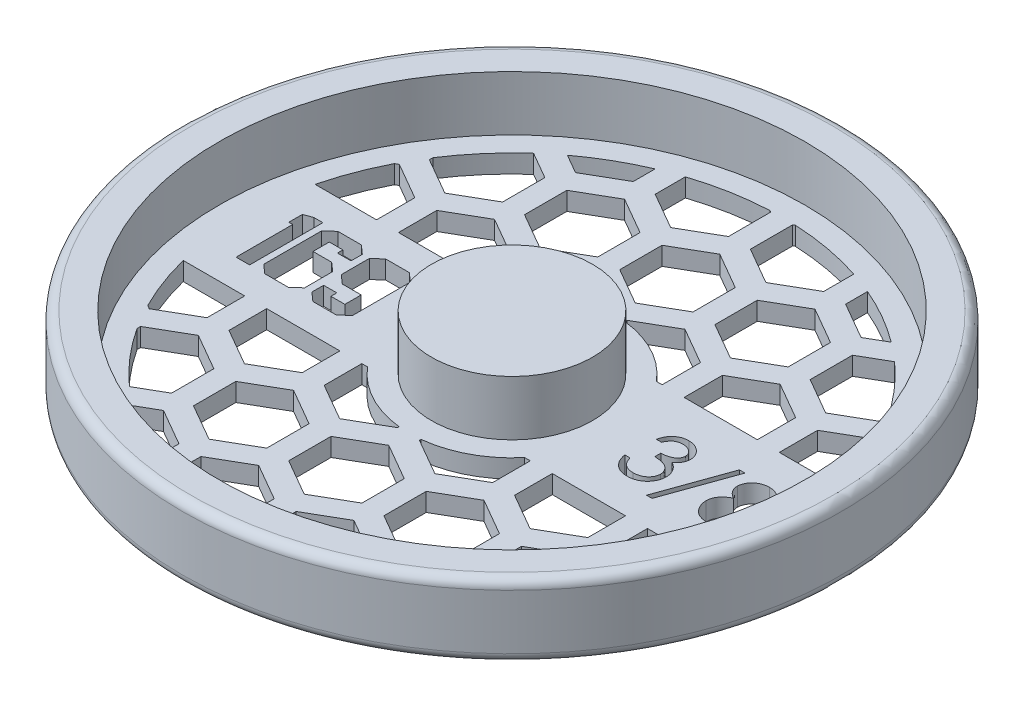
from build123d import *

# Parameters (mm, degrees)
CUT_EXTRUDE2_DEPTH      = 10.525
CUT_EXTRUDE2_DEPTH_BACK = 4.175
CUT_EXTRUDE4_DEPTH      = 10.525
CUT_EXTRUDE4_DEPTH_BACK = 4.1750001


with BuildPart() as part:
    # Sketch1 → Revolve1 (revolve)
    with BuildSketch(Plane.XY):
        with BuildLine():
            Line((0, 0), (0, 12.7))
            Line((0, 12.7), (13.97, 12.7))
            Line((13.97, 12.7), (13.97, 3.175))
            Line((13.97, 3.175), (50.8, 3.175))
            Line((50.8, 3.175), (50.8, 12.7))
            Line((50.8, 12.7), (55.5625, 12.7))
            ThreePointArc((55.5625, 12.7), (56.685032015, 12.235032015), (57.15, 11.1125))
            Line((57.15, 11.1125), (57.15, 1.5875))
            ThreePointArc((57.15, 1.5875), (56.685032015, 0.464967985), (55.5625, 0))
            Line((55.5625, 0), (0, 0))
        make_face()
    revolve(axis=Axis((0, 0, 0), (0, 1, 0)))

    # Sketch3 → Cut-Extrude2 (cut, two sides)
    with BuildSketch(Plane(origin=(0, 3.175, 0), x_dir=(1, 0, 0), z_dir=(0, 1, 0))) as cut_extrude2_sk:
        Polygon((-22.636037344, -5.022991324), (-24.137904564, -6.35), (-28.181208978, -6.35), (-29.68547152, -5.022991324), (-29.68547152, -2.979781215), (-27.397938514, -2.979781215), (-27.397938514, -4.004979253), (-24.978662769, -4.004979253), (-24.978662769, -1.176103357), (-28.253068653, -1.176103357), (-29.750145228, 0.150905319), (-29.750145228, 5.015805356), (-28.253068653, 6.35), (-24.154671822, 6.35), (-22.636037344, 5.008619389), align=None)
        Polygon((-30.945411166, -5.022991324), (-32.449673708, -6.35), (-36.524117314, -6.35), (-38.028379857, -5.022991324), (-38.028379857, 5.015805356), (-36.540884572, 6.35), (-32.473626933, 6.35), (-30.969364391, 5.015805356), (-30.969364391, 3.05164089), (-33.321571105, 3.05164089), (-33.321571105, 4.004979253), (-35.68335911, 4.004979253), (-35.68335911, 1.176103357), (-32.449673708, 1.176103357), (-30.945411166, -0.141324029), align=None)
        Polygon((-39.151786118, -6.35), (-41.496806865, -6.35), (-41.496806865, 3.463636364), (-42.167497171, 3.463636364), (-42.167497171, 5.808657111), (-40.720722369, 6.35), (-39.151786118, 6.35), align=None)
        with BuildLine():
            Line((23.201923077, 2.735384615), (22.290128205, 2.735384615))
            add(Edge.make_bspline(
                [(22.290128205, 2.735384615), (22.314830215, 2.837659483), (22.363120624, 3.037598484), (22.463842723, 3.323260704), (22.573568561, 3.593584984), (22.705326647, 3.843509586), (22.849043488, 4.078057258), (23.013701446, 4.291908202), (23.19170384, 4.490501268), (23.388589979, 4.666743123), (23.595066322, 4.826335617), (23.814042247, 4.962407212), (24.041112133, 5.079462467), (24.277849227, 5.175896054), (24.524958343, 5.248541575), (24.780205478, 5.301248187), (25.044259524, 5.335476107), (25.223503958, 5.338816608), (25.314519231, 5.340512821)],
                knots=[0, 0, 0, 0, 0.000315438, 0.000616656, 0.000907698, 0.001189895, 0.001463234, 0.001731895, 0.001998452, 0.002262133, 0.002523472, 0.002780414, 0.003034373, 0.003289106, 0.00354604, 0.003805892, 0.004070452, 0.004343366, 0.004343366, 0.004343366, 0.004343366], degree=3))
            add(Edge.make_bspline(
                [(25.314519231, 5.340512821), (25.447129705, 5.336509112), (25.709458034, 5.328589028), (26.094850193, 5.256265978), (26.466493759, 5.141820451), (26.820320833, 4.983691003), (27.148977769, 4.788655831), (27.441400528, 4.556529623), (27.693625462, 4.29179108), (27.905227427, 3.999378836), (28.070907996, 3.686870271), (28.193078726, 3.365233244), (28.267454805, 3.035230721), (28.277093907, 2.812415305), (28.281923077, 2.700785256)],
                knots=[0, 0, 0, 0, 0.000397506, 0.000786341, 0.001171951, 0.001561898, 0.001946195, 0.002315542, 0.002678309, 0.003039829, 0.003394922, 0.003736275, 0.004069616, 0.004404291, 0.004404291, 0.004404291, 0.004404291], degree=3))
            add(Edge.make_bspline(
                [(28.281923077, 2.700785256), (28.278545338, 2.593359818), (28.271935628, 2.383144906), (28.215812643, 2.076250503), (28.12136452, 1.787005171), (27.990533437, 1.514191284), (27.821176252, 1.259538606), (27.616023509, 1.022474191), (27.37362721, 0.801946578), (27.189937493, 0.675615765), (27.09536859, 0.610576923)],
                knots=[0, 0, 0, 0, 0.000322092, 0.000630284, 0.00093214, 0.001232539, 0.001535102, 0.001846808, 0.002171002, 0.002515015, 0.002515015, 0.002515015, 0.002515015], degree=3))
            add(Edge.make_bspline(
                [(27.09536859, 0.610576923), (27.203447054, 0.558388859), (27.417581752, 0.454989211), (27.709465575, 0.252207926), (27.974432208, 0.018074072), (28.122198432, -0.164639457), (28.196442308, -0.256442308)],
                knots=[0, 0, 0, 0, 0.000359556, 0.000712384, 0.001062596, 0.001416244, 0.001416244, 0.001416244, 0.001416244], degree=3))
            add(Edge.make_bspline(
                [(28.196442308, -0.256442308), (28.245330319, -0.323375667), (28.342305765, -0.456146304), (28.462006629, -0.669612044), (28.570599944, -0.885443795), (28.655218866, -1.109426528), (28.720747577, -1.338964191), (28.767588173, -1.574450918), (28.796686822, -1.816079006), (28.800854025, -1.979546091), (28.802948718, -2.061714744)],
                knots=[0, 0, 0, 0, 0.000248435, 0.000492801, 0.000733099, 0.000972742, 0.001209812, 0.001448502, 0.001692367, 0.001938844, 0.001938844, 0.001938844, 0.001938844], degree=3))
            add(Edge.make_bspline(
                [(28.802948718, -2.061714744), (28.797739502, -2.203982963), (28.787345583, -2.487849885), (28.694442328, -2.907239362), (28.550422178, -3.31719682), (28.345895758, -3.709299782), (28.096634646, -4.076163974), (27.800086528, -4.404408345), (27.45962084, -4.686562008), (27.079910728, -4.922303699), (26.668526149, -5.110751153), (26.228523859, -5.241546473), (25.766243702, -5.326733718), (25.449230519, -5.335868628), (25.288060897, -5.340512821)],
                knots=[0, 0, 0, 0, 0.000426322, 0.000850637, 0.001282577, 0.001726786, 0.002173324, 0.002609918, 0.00304927, 0.003495414, 0.003947167, 0.00440236, 0.004869477, 0.005352558, 0.005352558, 0.005352558, 0.005352558], degree=3))
            add(Edge.make_bspline(
                [(25.288060897, -5.340512821), (25.179438014, -5.337992521), (24.965704402, -5.333033413), (24.651488989, -5.299132102), (24.351560856, -5.237214144), (24.065514481, -5.153892549), (23.793095747, -5.048252521), (23.535135944, -4.916698815), (23.290048025, -4.76194314), (23.060144784, -4.582158782), (22.845453627, -4.38104495), (22.651680005, -4.155031367), (22.475593292, -3.908296046), (22.321908375, -3.637973117), (22.183625107, -3.347556028), (22.069888387, -3.033326101), (21.969781707, -2.698092483), (21.923238851, -2.4644771), (21.899358974, -2.344615385)],
                knots=[0, 0, 0, 0, 0.00032587, 0.000641203, 0.000946553, 0.001243456, 0.001534099, 0.001821726, 0.002110819, 0.002402315, 0.002696028, 0.002991841, 0.003293972, 0.003603973, 0.003923534, 0.004257744, 0.004605529, 0.004971988, 0.004971988, 0.004971988, 0.004971988], degree=3))
            Line((21.899358974, -2.344615385), (22.811153846, -2.344615385))
            add(Edge.make_bspline(
                [(22.811153846, -2.344615385), (22.834908772, -2.42284452), (22.881114167, -2.575006984), (22.959765043, -2.793999414), (23.049371227, -2.994755363), (23.14549806, -3.178747512), (23.246454921, -3.347787857), (23.359419389, -3.49740654), (23.476024679, -3.634175241), (23.563921316, -3.711230457), (23.606939103, -3.748942308)],
                knots=[0, 0, 0, 0, 0.000245255, 0.000477042, 0.000697536, 0.000904182, 0.001099652, 0.001287304, 0.001466129, 0.001637538, 0.001637538, 0.001637538, 0.001637538], degree=3))
            add(Edge.make_bspline(
                [(23.606939103, -3.748942308), (23.663825165, -3.792799643), (23.777421695, -3.880378935), (23.96253176, -3.992143662), (24.157211543, -4.088985953), (24.365679283, -4.162961481), (24.583436446, -4.225598348), (24.81400274, -4.266588198), (25.05534401, -4.294711575), (25.220132718, -4.297193319), (25.304342949, -4.298461538)],
                knots=[0, 0, 0, 0, 0.000215334, 0.000430002, 0.000647547, 0.000866467, 0.001092637, 0.001326558, 0.001568172, 0.001820675, 0.001820675, 0.001820675, 0.001820675], degree=3))
            add(Edge.make_bspline(
                [(25.304342949, -4.298461538), (25.399421688, -4.296673654), (25.585339954, -4.293177599), (25.85662606, -4.261026404), (26.114711679, -4.214202118), (26.356731373, -4.141883288), (26.58585536, -4.052530874), (26.798871805, -3.940340074), (26.998577074, -3.808710825), (27.182413291, -3.65910001), (27.347717964, -3.49531647), (27.493265808, -3.324009955), (27.616999111, -3.145902747), (27.716809727, -2.96000923), (27.795623895, -2.767099194), (27.849277986, -2.566631278), (27.886584099, -2.360246071), (27.889622264, -2.219953979), (27.891153846, -2.149230769)],
                knots=[0, 0, 0, 0, 0.000285118, 0.000557523, 0.000818576, 0.001071029, 0.001314045, 0.001555289, 0.001791808, 0.002030524, 0.002265109, 0.002488959, 0.002704052, 0.002914404, 0.003120759, 0.003327646, 0.003536098, 0.003748009, 0.003748009, 0.003748009, 0.003748009], degree=3))
            add(Edge.make_bspline(
                [(27.891153846, -2.149230769), (27.886711599, -2.054564711), (27.87784921, -1.86570364), (27.810187734, -1.587849196), (27.698895488, -1.320137805), (27.543091855, -1.067136997), (27.353431568, -0.832656094), (27.131755153, -0.623442877), (26.876221782, -0.450809698), (26.641032676, -0.331535198), (26.432708679, -0.250147574), (26.254428591, -0.19593682), (26.054837994, -0.150032037), (25.836350536, -0.107324414), (25.597319942, -0.07097673), (25.338006442, -0.04066563), (25.058357488, -0.01641214), (24.864762561, -0.005581303), (24.765, 0)],
                knots=[0, 0, 0, 0, 0.000283785, 0.000566158, 0.00085266, 0.001150399, 0.001454273, 0.001755223, 0.002061196, 0.002376128, 0.002544317, 0.00273166, 0.002934554, 0.003158479, 0.003399405, 0.003659679, 0.003941605, 0.004241348, 0.004241348, 0.004241348, 0.004241348], degree=3))
            Line((24.765, 0), (24.765, 1.042051282))
            add(Edge.make_bspline(
                [(24.765, 1.042051282), (24.890697098, 1.044184312), (25.136906836, 1.048362395), (25.496554303, 1.098895362), (25.840465404, 1.168797985), (26.16101846, 1.275870429), (26.453187297, 1.400229691), (26.706663627, 1.544943533), (26.917896261, 1.705804634), (27.085858685, 1.885295865), (27.212217818, 2.077798975), (27.304606464, 2.278434758), (27.359181125, 2.488961746), (27.36646633, 2.632637697), (27.370128205, 2.704855769)],
                knots=[0, 0, 0, 0, 0.000376792, 0.000738043, 0.001087728, 0.0014282, 0.001749964, 0.002039013, 0.002301593, 0.002543523, 0.002772704, 0.002989485, 0.00320372, 0.003420233, 0.003420233, 0.003420233, 0.003420233], degree=3))
            add(Edge.make_bspline(
                [(27.370128205, 2.704855769), (27.368925229, 2.757913452), (27.366531966, 2.863469196), (27.336350154, 3.017683681), (27.290995795, 3.16718357), (27.228643209, 3.311333099), (27.14518549, 3.449132523), (27.045309826, 3.58175666), (26.926385283, 3.708448316), (26.790109357, 3.826537472), (26.643771089, 3.939079029), (26.483388885, 4.034622616), (26.313798529, 4.11632371), (26.134812262, 4.183697579), (25.945849237, 4.234379399), (25.747797287, 4.270769155), (25.540278754, 4.293520747), (25.398701383, 4.296796377), (25.326730769, 4.298461538)],
                knots=[0, 0, 0, 0, 0.000158959, 0.000316241, 0.000469467, 0.000627144, 0.000785959, 0.000951629, 0.001124422, 0.00130612, 0.001492143, 0.001677485, 0.001865005, 0.002056287, 0.00225032, 0.00245111, 0.00265991, 0.002875801, 0.002875801, 0.002875801, 0.002875801], degree=3))
            add(Edge.make_bspline(
                [(25.326730769, 4.298461538), (25.21104707, 4.294422613), (24.9850899, 4.286533653), (24.659346027, 4.217436906), (24.356521903, 4.107191955), (24.125051945, 3.975596675), (23.954124244, 3.845692559), (23.831980903, 3.732241974), (23.712033365, 3.606162692), (23.602172771, 3.459689237), (23.491068885, 3.302741069), (23.3899201, 3.127339753), (23.291630251, 2.938060711), (23.232404564, 2.804251669), (23.201923077, 2.735384615)],
                knots=[0, 0, 0, 0, 0.000346717, 0.000677219, 0.00099404, 0.001310351, 0.001471548, 0.001637205, 0.001809999, 0.001992787, 0.002185868, 0.002386576, 0.002599579, 0.002825456, 0.002825456, 0.002825456, 0.002825456], degree=3))
        make_face()
        Polygon((35.05525641, 5.340512821), (30.805641026, -6.512820513), (29.845, -6.512820513), (34.094615385, 5.340512821), align=None)
        with BuildLine():
            add(Edge.make_bspline(
                [(40.776362179, 0.580048077), (40.859524819, 0.536685325), (41.02171974, 0.452113476), (41.252721008, 0.315938045), (41.463831297, 0.172417987), (41.660907899, 0.028332178), (41.840488369, -0.121837416), (42.000564722, -0.278687949), (42.14509107, -0.438304293), (42.27115282, -0.603389315), (42.38203278, -0.773504433), (42.477862293, -0.949096152), (42.559772801, -1.129779658), (42.624689218, -1.317527256), (42.678165047, -1.509581044), (42.714960518, -1.7084209), (42.734749057, -1.912736586), (42.738490298, -2.050820571), (42.740384615, -2.120737179)],
                knots=[0, 0, 0, 0, 0.000281344, 0.000548715, 0.000803862, 0.001046877, 0.001280887, 0.001505412, 0.001718716, 0.001926323, 0.002127854, 0.00232732, 0.002525911, 0.002722237, 0.002922697, 0.003123487, 0.003328028, 0.003537817, 0.003537817, 0.003537817, 0.003537817], degree=3))
            add(Edge.make_bspline(
                [(42.740384615, -2.120737179), (42.738145292, -2.218556883), (42.73371283, -2.412178781), (42.695104876, -2.697953779), (42.637300345, -2.975501123), (42.552886675, -3.244759965), (42.443410089, -3.504244546), (42.308494473, -3.754176985), (42.155771661, -3.998653608), (42.033119446, -4.149077928), (41.971057692, -4.225192308)],
                knots=[0, 0, 0, 0, 0.000293331, 0.000580613, 0.00086363, 0.001143002, 0.001425749, 0.001707093, 0.001994468, 0.002288822, 0.002288822, 0.002288822, 0.002288822], degree=3))
            add(Edge.make_bspline(
                [(41.971057692, -4.225192308), (41.890252384, -4.314001664), (41.729640301, -4.490522934), (41.454499003, -4.719705856), (41.152538334, -4.912308669), (40.824926717, -5.069271654), (40.472539886, -5.19144089), (40.095452924, -5.2792306), (39.692930697, -5.329515137), (39.416272529, -5.336783861), (39.274342949, -5.340512821)],
                knots=[0, 0, 0, 0, 0.00035989, 0.000715332, 0.001070453, 0.001431842, 0.001802594, 0.002187171, 0.002591332, 0.003017095, 0.003017095, 0.003017095, 0.003017095], degree=3))
            add(Edge.make_bspline(
                [(39.274342949, -5.340512821), (39.137869798, -5.337167342), (38.872306908, -5.33065738), (38.485768612, -5.286550115), (38.125457072, -5.209253222), (37.789277278, -5.103459728), (37.479255929, -4.965834608), (37.196276412, -4.794541627), (36.936255967, -4.596475498), (36.707085632, -4.365947774), (36.503628892, -4.119036922), (36.32490563, -3.864306534), (36.17635459, -3.601733359), (36.050582222, -3.335232591), (35.954300191, -3.061068897), (35.887615146, -2.780652859), (35.845264451, -2.494474273), (35.839629614, -2.301342388), (35.836794872, -2.204182692)],
                knots=[0, 0, 0, 0, 0.00040941, 0.000796671, 0.00116512, 0.001513339, 0.001852245, 0.002179997, 0.002503628, 0.002830317, 0.003152666, 0.003462627, 0.003762528, 0.004056635, 0.004345649, 0.004632454, 0.004920283, 0.005211673, 0.005211673, 0.005211673, 0.005211673], degree=3))
            add(Edge.make_bspline(
                [(35.836794872, -2.204182692), (35.838472378, -2.132890866), (35.841787722, -1.991993055), (35.864734367, -1.783831119), (35.901625215, -1.581222911), (35.951726952, -1.383420066), (36.01962776, -1.191862635), (36.101610638, -1.005642974), (36.197207392, -0.824550847), (36.307751574, -0.647595924), (36.436354021, -0.477257683), (36.58197193, -0.31064531), (36.747515686, -0.150344118), (36.931143633, 0.005604407), (37.130757267, 0.159966662), (37.351541413, 0.304400434), (37.587643173, 0.449130983), (37.755444008, 0.535660294), (37.841522436, 0.580048077)],
                knots=[0, 0, 0, 0, 0.000213857, 0.000422657, 0.000627451, 0.000831322, 0.001034083, 0.001236394, 0.001441238, 0.001647914, 0.001861616, 0.002080839, 0.00231112, 0.002552184, 0.002803347, 0.003067523, 0.003343268, 0.003633711, 0.003633711, 0.003633711, 0.003633711], degree=3))
            add(Edge.make_bspline(
                [(37.841522436, 0.580048077), (37.723691474, 0.644302148), (37.495537751, 0.768716015), (37.19343903, 0.997306743), (36.933950821, 1.244885086), (36.724205697, 1.516679004), (36.559113744, 1.804197931), (36.445848309, 2.105642961), (36.369223087, 2.415424593), (36.361632617, 2.627060866), (36.357820513, 2.733349359)],
                knots=[0, 0, 0, 0, 0.000402147, 0.00077867, 0.001132746, 0.001475117, 0.001805061, 0.002123317, 0.002438788, 0.002757076, 0.002757076, 0.002757076, 0.002757076], degree=3))
            add(Edge.make_bspline(
                [(36.357820513, 2.733349359), (36.362567915, 2.841618843), (36.372111022, 3.059259387), (36.449278604, 3.383236019), (36.575030569, 3.701437248), (36.746069806, 4.012320803), (36.959102411, 4.305364855), (37.214688955, 4.568192287), (37.506725954, 4.798422191), (37.833755648, 4.991683309), (38.185687121, 5.14897073), (38.557008193, 5.257474952), (38.941249213, 5.328409508), (39.202790022, 5.336440711), (39.335400641, 5.340512821)],
                knots=[0, 0, 0, 0, 0.000324526, 0.000652354, 0.000993264, 0.001348502, 0.001714062, 0.002076772, 0.002444855, 0.002826361, 0.003213622, 0.003598048, 0.003984522, 0.004382028, 0.004382028, 0.004382028, 0.004382028], degree=3))
            add(Edge.make_bspline(
                [(39.335400641, 5.340512821), (39.464588858, 5.336314293), (39.719333305, 5.328035275), (40.093786281, 5.258985366), (40.452071068, 5.143656246), (40.792952128, 4.987200307), (41.11032692, 4.794488501), (41.390749624, 4.56109625), (41.638457919, 4.299428205), (41.843354332, 4.006473014), (42.012192891, 3.69678404), (42.129761221, 3.372759808), (42.205096094, 3.041401397), (42.214598203, 2.817190506), (42.219358974, 2.704855769)],
                knots=[0, 0, 0, 0, 0.000387346, 0.000763803, 0.001137764, 0.00151389, 0.001886692, 0.002248132, 0.002605226, 0.002964378, 0.003317675, 0.003660227, 0.003995557, 0.004332261, 0.004332261, 0.004332261, 0.004332261], degree=3))
            add(Edge.make_bspline(
                [(42.219358974, 2.704855769), (42.21519465, 2.594614939), (42.207016153, 2.378108215), (42.138218614, 2.062490658), (42.022355967, 1.766915825), (41.864167197, 1.48802977), (41.657990353, 1.230890337), (41.406577573, 0.99222767), (41.111933282, 0.77008122), (40.890558824, 0.644717374), (40.776362179, 0.580048077)],
                knots=[0, 0, 0, 0, 0.000330471, 0.000649026, 0.000963484, 0.001279795, 0.001607187, 0.00194834, 0.002317535, 0.002710909, 0.002710909, 0.002710909, 0.002710909], degree=3))
        make_face()
    extrude(amount=CUT_EXTRUDE2_DEPTH, mode=Mode.SUBTRACT)
    extrude(cut_extrude2_sk.sketch, amount=-CUT_EXTRUDE2_DEPTH_BACK, mode=Mode.SUBTRACT)

    # Sketch4 → Cut-Extrude4 (cut, two sides)
    with BuildSketch(Plane(origin=(0, 3.175, 0), x_dir=(1, 0, 0), z_dir=(0, 1, 0))) as cut_extrude4_sk:
        with BuildLine():
            Line((-45.57867045, 11.43), (-34.925, 11.43))
            Line((-34.925, 11.43), (-34.925, 18.070094793))
            Line((-34.925, 18.070094793), (-41.275, 21.736269002))
            Line((-41.275, 21.736269002), (-41.824450692, 21.419043498))
            ThreePointArc((-41.824450692, 21.419043498), (-43.986039192, 16.531438418), (-45.57867045, 11.43))
        make_face()
        Polygon((-31.115, 11.43), (-18.415, 11.43), (-18.415, 18.070094793), (-24.765, 21.736269002), (-31.115, 18.070094793), align=None)
        with BuildLine():
            ThreePointArc((-31.304627771, 35.043977801), (-35.647925291, 30.61511918), (-39.37, 25.652742543))
            Line((-39.37, 25.652742543), (-39.37, 25.035825791))
            Line((-39.37, 25.035825791), (-33.02, 21.369651581))
            Line((-33.02, 21.369651581), (-26.67, 25.035825791))
            Line((-26.67, 25.035825791), (-26.67, 32.368174209))
            Line((-26.67, 32.368174209), (-31.304627771, 35.043977801))
        make_face()
        with BuildLine():
            ThreePointArc((-18.415, 43.231329785), (-23.408586329, 40.744302498), (-28.072243454, 37.683010063))
            Line((-28.072243454, 37.683010063), (-24.765, 35.773572165))
            Line((-24.765, 35.773572165), (-18.415, 39.439746374))
            Line((-18.415, 39.439746374), (-18.415, 43.231329785))
        make_face()
        Polygon((-16.51, 36.034348419), (-22.86, 32.368174209), (-22.86, 25.035825791), (-16.51, 21.369651581), (-10.16, 25.035825791), (-10.16, 32.368174209), align=None)
        with BuildLine():
            Line((-1.905, 46.772094793), (-2.193684728, 46.938766998))
            ThreePointArc((-2.193684728, 46.938766998), (-8.476090298, 46.21921671), (-14.605, 44.662669815))
            Line((-14.605, 44.662669815), (-14.605, 39.439746374))
            Line((-14.605, 39.439746374), (-8.255, 35.773572165))
            Line((-8.255, 35.773572165), (-1.905, 39.439746374))
            Line((-1.905, 39.439746374), (-1.905, 46.772094793))
        make_face()
        Polygon((-6.35, 25.035825791), (0, 21.369651581), (6.35, 25.035825791), (6.35, 32.368174209), (0, 36.034348419), (-6.35, 32.368174209), align=None)
        with BuildLine():
            ThreePointArc((-13.619232724, 11.43), (-8.367122494, 15.688201336), (-1.905, 17.677651852))
            Line((-1.905, 17.677651852), (-1.905, 18.070094793))
            Line((-1.905, 18.070094793), (-8.255, 21.736269002))
            Line((-8.255, 21.736269002), (-14.605, 18.070094793))
            Line((-14.605, 18.070094793), (-14.605, 11.43))
            Line((-14.605, 11.43), (-13.619232724, 11.43))
        make_face()
        with BuildLine():
            ThreePointArc((1.905, 17.677651852), (8.367122494, 15.688201336), (13.619232724, 11.43))
            Line((13.619232724, 11.43), (14.605, 11.43))
            Line((14.605, 11.43), (14.605, 18.070094793))
            Line((14.605, 18.070094793), (8.255, 21.736269002))
            Line((8.255, 21.736269002), (1.905, 18.070094793))
            Line((1.905, 18.070094793), (1.905, 17.677651852))
        make_face()
        with BuildLine():
            Line((14.605, 39.439746374), (14.605, 44.662669815))
            ThreePointArc((14.605, 44.662669815), (8.476090298, 46.21921671), (2.193684728, 46.938766998))
            Line((2.193684728, 46.938766998), (1.905, 46.772094793))
            Line((1.905, 46.772094793), (1.905, 39.439746374))
            Line((1.905, 39.439746374), (8.255, 35.773572165))
            Line((8.255, 35.773572165), (14.605, 39.439746374))
        make_face()
        Polygon((16.51, 36.034348419), (10.16, 32.368174209), (10.16, 25.035825791), (16.51, 21.369651581), (22.86, 25.035825791), (22.86, 32.368174209), align=None)
        with BuildLine():
            Line((24.765, 35.773572165), (28.072243454, 37.683010063))
            ThreePointArc((28.072243454, 37.683010063), (23.408586329, 40.744302498), (18.415, 43.231329785))
            Line((18.415, 43.231329785), (18.415, 39.439746374))
            Line((18.415, 39.439746374), (24.765, 35.773572165))
        make_face()
        with BuildLine():
            Line((39.37, 25.035825791), (39.37, 25.652742543))
            ThreePointArc((39.37, 25.652742543), (35.647925291, 30.61511918), (31.304627771, 35.043977801))
            Line((31.304627771, 35.043977801), (26.67, 32.368174209))
            Line((26.67, 32.368174209), (26.67, 25.035825791))
            Line((26.67, 25.035825791), (33.02, 21.369651581))
            Line((33.02, 21.369651581), (39.37, 25.035825791))
        make_face()
        Polygon((18.415, 18.070094793), (18.415, 11.43), (31.115, 11.43), (31.115, 18.070094793), (24.765, 21.736269002), align=None)
        with BuildLine():
            Line((34.925, 18.070094793), (34.925, 11.43))
            Line((34.925, 11.43), (45.57867045, 11.43))
            ThreePointArc((45.57867045, 11.43), (43.986039192, 16.531438418), (41.824450692, 21.419043498))
            Line((41.824450692, 21.419043498), (41.275, 21.736269002))
            Line((41.275, 21.736269002), (34.925, 18.070094793))
        make_face()
        with BuildLine():
            Line((45.57867045, -11.43), (34.925, -11.43))
            Line((34.925, -11.43), (34.925, -17.964253626))
            Line((34.925, -17.964253626), (41.275, -21.630427835))
            Line((41.275, -21.630427835), (41.900926719, -21.269048875))
            ThreePointArc((41.900926719, -21.269048875), (44.01558475, -16.452610707), (45.57867045, -11.43))
        make_face()
        Polygon((31.115, -11.43), (18.415, -11.43), (18.415, -17.964253626), (24.765, -21.630427835), (31.115, -17.964253626), align=None)
        with BuildLine():
            Line((14.605, -11.43), (13.619232724, -11.43))
            ThreePointArc((13.619232724, -11.43), (8.367122494, -15.688201336), (1.905, -17.677651852))
            Line((1.905, -17.677651852), (1.905, -17.964253626))
            Line((1.905, -17.964253626), (8.255, -21.630427835))
            Line((8.255, -21.630427835), (14.605, -17.964253626))
            Line((14.605, -17.964253626), (14.605, -11.43))
        make_face()
        with BuildLine():
            ThreePointArc((31.304627771, -35.043977801), (35.647925291, -30.61511918), (39.37, -25.652742543))
            Line((39.37, -25.652742543), (39.37, -25.035825791))
            Line((39.37, -25.035825791), (33.02, -21.369651581))
            Line((33.02, -21.369651581), (26.67, -25.035825791))
            Line((26.67, -25.035825791), (26.67, -32.368174209))
            Line((26.67, -32.368174209), (31.304627771, -35.043977801))
        make_face()
        with BuildLine():
            ThreePointArc((18.415, -43.231329785), (23.451826011, -40.719429721), (28.152186338, -37.623323942))
            Line((28.152186338, -37.623323942), (24.765, -35.667730998))
            Line((24.765, -35.667730998), (18.415, -39.333905207))
            Line((18.415, -39.333905207), (18.415, -43.231329785))
        make_face()
        Polygon((16.51, -21.369651581), (10.16, -25.035825791), (10.16, -32.368174209), (16.51, -36.034348419), (22.86, -32.368174209), (22.86, -25.035825791), align=None)
        with BuildLine():
            ThreePointArc((2.362789552, -46.930558547), (8.559339951, -46.203872128), (14.605, -44.662669815))
            Line((14.605, -44.662669815), (14.605, -39.333905207))
            Line((14.605, -39.333905207), (8.255, -35.667730998))
            Line((8.255, -35.667730998), (1.905, -39.333905207))
            Line((1.905, -39.333905207), (1.905, -46.666253626))
            Line((1.905, -46.666253626), (2.362789552, -46.930558547))
        make_face()
        Polygon((-6.35, -32.368174209), (0, -36.034348419), (6.35, -32.368174209), (6.35, -25.035825791), (0, -21.369651581), (-6.35, -25.035825791), align=None)
        with BuildLine():
            ThreePointArc((-14.605, -44.662669815), (-8.559339951, -46.203872128), (-2.362789552, -46.930558547))
            Line((-2.362789552, -46.930558547), (-1.905, -46.666253626))
            Line((-1.905, -46.666253626), (-1.905, -39.333905207))
            Line((-1.905, -39.333905207), (-8.255, -35.667730998))
            Line((-8.255, -35.667730998), (-14.605, -39.333905207))
            Line((-14.605, -39.333905207), (-14.605, -44.662669815))
        make_face()
        Polygon((-16.51, -21.369651581), (-22.86, -25.035825791), (-22.86, -32.368174209), (-16.51, -36.034348419), (-10.16, -32.368174209), (-10.16, -25.035825791), align=None)
        with BuildLine():
            Line((-24.765, -35.667730998), (-28.152186338, -37.623323942))
            ThreePointArc((-28.152186338, -37.623323942), (-23.451826011, -40.719429721), (-18.415, -43.231329785))
            Line((-18.415, -43.231329785), (-18.415, -39.333905207))
            Line((-18.415, -39.333905207), (-24.765, -35.667730998))
        make_face()
        with BuildLine():
            Line((-39.37, -25.035825791), (-39.37, -25.652742543))
            ThreePointArc((-39.37, -25.652742543), (-35.647925291, -30.61511918), (-31.304627771, -35.043977801))
            Line((-31.304627771, -35.043977801), (-26.67, -32.368174209))
            Line((-26.67, -32.368174209), (-26.67, -25.035825791))
            Line((-26.67, -25.035825791), (-33.02, -21.369651581))
            Line((-33.02, -21.369651581), (-39.37, -25.035825791))
        make_face()
        with BuildLine():
            Line((-34.925, -17.964253626), (-34.925, -11.43))
            Line((-34.925, -11.43), (-45.57867045, -11.43))
            ThreePointArc((-45.57867045, -11.43), (-44.01558475, -16.452610707), (-41.900926719, -21.269048875))
            Line((-41.900926719, -21.269048875), (-41.275, -21.630427835))
            Line((-41.275, -21.630427835), (-34.925, -17.964253626))
        make_face()
        Polygon((-18.415, -17.964253626), (-18.415, -11.43), (-31.115, -11.43), (-31.115, -17.964253626), (-24.765, -21.630427835), align=None)
        with BuildLine():
            Line((-1.905, -17.964253626), (-1.905, -17.677651852))
            ThreePointArc((-1.905, -17.677651852), (-8.367122494, -15.688201336), (-13.619232724, -11.43))
            Line((-13.619232724, -11.43), (-14.605, -11.43))
            Line((-14.605, -11.43), (-14.605, -17.964253626))
            Line((-14.605, -17.964253626), (-8.255, -21.630427835))
            Line((-8.255, -21.630427835), (-1.905, -17.964253626))
        make_face()
    extrude(amount=CUT_EXTRUDE4_DEPTH, mode=Mode.SUBTRACT)
    extrude(cut_extrude4_sk.sketch, amount=-CUT_EXTRUDE4_DEPTH_BACK, mode=Mode.SUBTRACT)


solid = part.part
